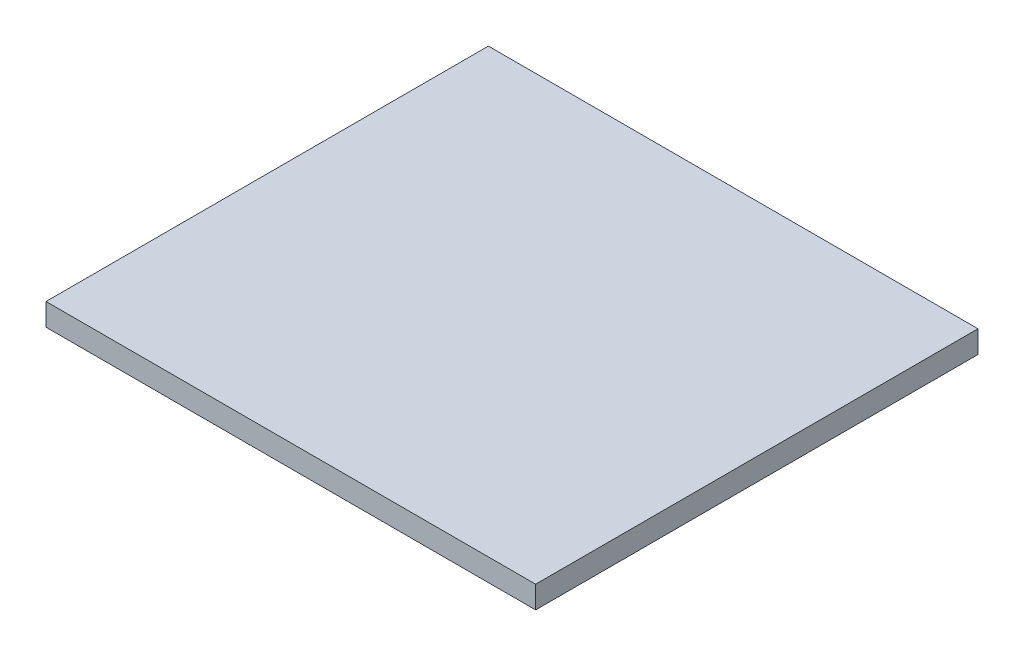
from build123d import *

# Parameters (mm, degrees)
SKETCH1_W           = 139.446
SKETCH1_H           = 125.984
BOSS_EXTRUDE1_DEPTH = 6.35


with BuildPart() as part:
    # Sketch1 → Boss-Extrude1 (new body)
    with BuildSketch(Plane(origin=(0, 0, 0), x_dir=(1, 0, 0), z_dir=(0, 1, 0))):
        with Locations((7.303154507, 8.327820245)):
            Rectangle(SKETCH1_W, SKETCH1_H)
    extrude(amount=BOSS_EXTRUDE1_DEPTH)


solid = part.part
